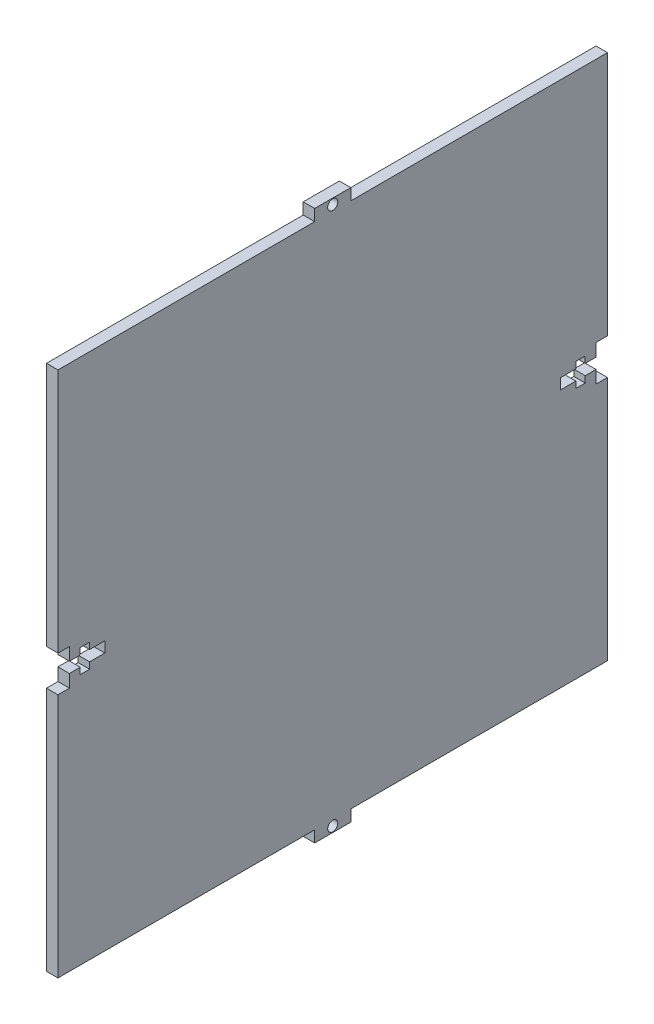
from build123d import *

# Parameters (mm, degrees)
SKETCH1_W           = 152.4
SKETCH1_H           = 146.04
BOSS_EXTRUDE1_DEPTH = 3.18
SKETCH3_R           = 1.4
SKETCH3_W           = 10
SKETCH3_H           = 3.18
BOSS_EXTRUDE5_DEPTH = 3.18
CUT_EXTRUDE2_DEPTH  = 4.18
CUT_EXTRUDE3_DEPTH  = 4.18


with BuildPart() as part:
    # Sketch1 → Boss-Extrude1 (new body)
    with BuildSketch(Plane(origin=(0, 0, 0), x_dir=(0, 0, -1), z_dir=(1, 0, 0))):
        Rectangle(SKETCH1_W, SKETCH1_H)
    extrude(amount=BOSS_EXTRUDE1_DEPTH)

    # Sketch3 → Boss-Extrude5 (add)
    with BuildSketch(Plane.ZY):
        Polygon((0, 73.02), (5, 73.02), (5, 76.2), (-5, 76.2), (-5, 73.02), align=None)
        with Locations((0, 74.61)):
            Circle(SKETCH3_R, mode=Mode.SUBTRACT)
        with Locations((0, -74.61)):
            Rectangle(SKETCH3_W, SKETCH3_H)
        with Locations((0, -74.61)):
            Circle(SKETCH3_R, mode=Mode.SUBTRACT)
    extrude(amount=-BOSS_EXTRUDE5_DEPTH)

    # Sketch4 → Cut-Extrude2 (cut, through all)
    with BuildSketch(Plane(origin=(0, 0, 0), x_dir=(0, 0, -1), z_dir=(1, 0, 0))):
        Polygon((-76.2, -5), (-76.2, 5), (-73.02, 5), (-73.02, 1.47), (-70.02, 1.47), (-70.02, 3.25), (-67.42, 3.25), (-67.42, 1.47), (-63.2, 1.47), (-63.2, -1.47), (-67.42, -1.47), (-67.42, -3.25), (-70.02, -3.25), (-70.02, -1.47), (-73.02, -1.47), (-73.02, -5), align=None)
    extrude(amount=CUT_EXTRUDE2_DEPTH, mode=Mode.SUBTRACT)

    # Sketch5 → Cut-Extrude3 (cut, through all)
    with BuildSketch(Plane.ZY):
        Polygon((-70.02, -1.47), (-73.02, -1.47), (-73.02, -5), (-76.2, -5), (-76.2, 5), (-73.02, 5), (-73.02, 1.47), (-70.02, 1.47), (-70.02, 3.25), (-67.42, 3.25), (-67.42, 1.47), (-63.2, 1.47), (-63.2, -1.47), (-67.42, -1.47), (-67.42, -3.25), (-70.02, -3.25), align=None)
    extrude(amount=-CUT_EXTRUDE3_DEPTH, mode=Mode.SUBTRACT)


solid = part.part
